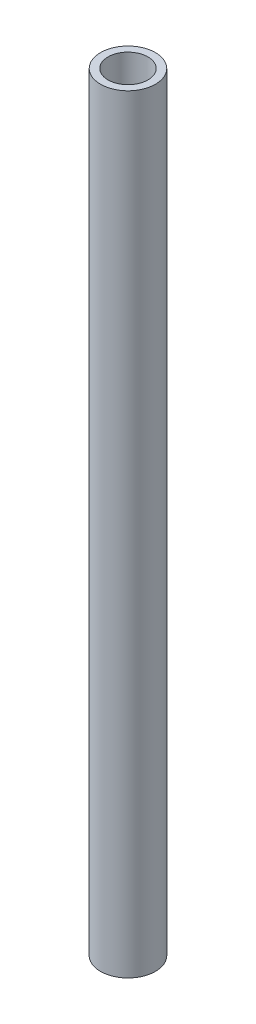
from build123d import *

# Parameters (mm, degrees)
SKETCH1_R           = 10.715
SKETCH1_R_2         = 7.8
BOSS_EXTRUDE1_DEPTH = 300


with BuildPart() as part:
    # Sketch1 → Boss-Extrude1 (new body)
    with BuildSketch(Plane(origin=(0, 0, 0), x_dir=(1, 0, 0), z_dir=(0, 1, 0))):
        with Locations(Location((0, 0, 0), (0, 0, 270))):  # turned: the seam where the file's is
            Circle(SKETCH1_R)
        with Locations(Location((0, 0, 0), (0, 0, 270))):  # turned: the seam where the file's is
            Circle(SKETCH1_R_2, mode=Mode.SUBTRACT)
    extrude(amount=BOSS_EXTRUDE1_DEPTH)


solid = part.part
